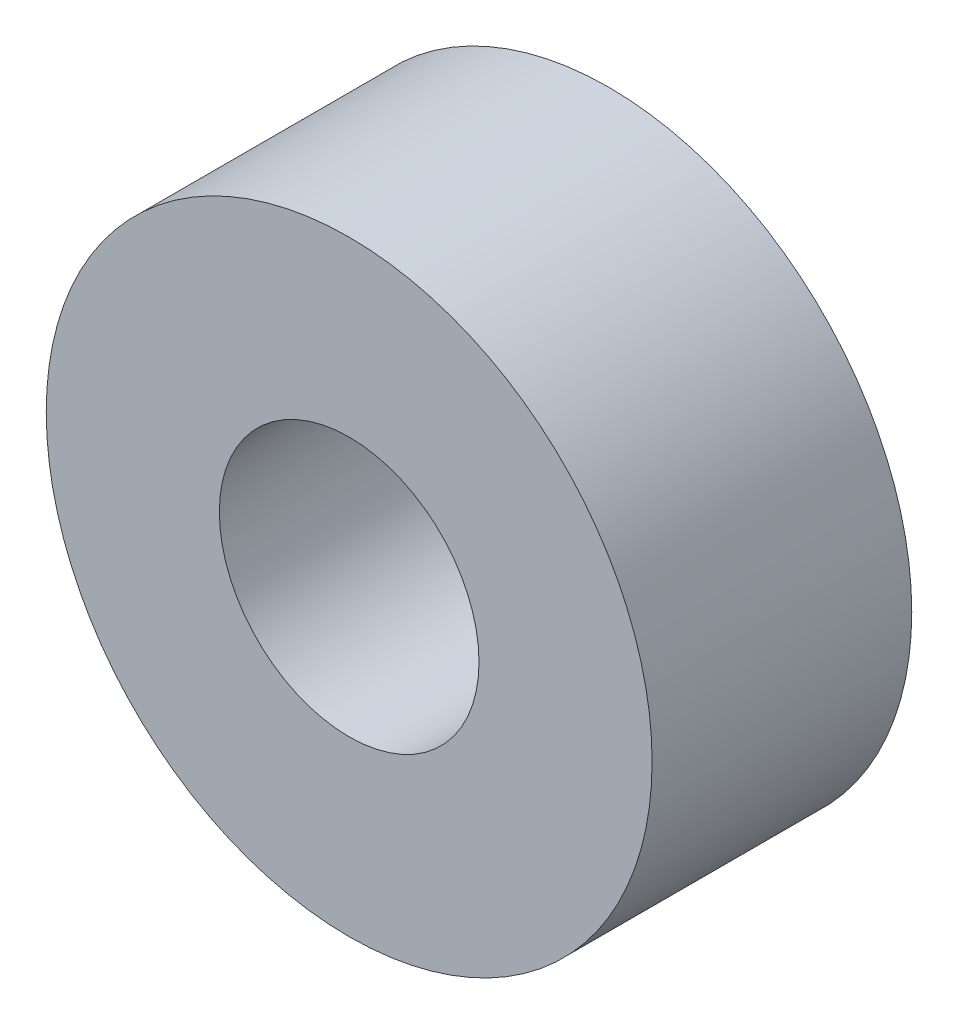
from build123d import *

# Parameters (mm, degrees)
ESQUISSE1_R        = 3.5
ESQUISSE1_R_2      = 1.5
BOSS_EXTRU_1_DEPTH = 3


with BuildPart() as part:
    # Esquisse1 → Boss.-Extru.1 (new body)
    with BuildSketch(Plane.XY):
        Circle(ESQUISSE1_R)
        Circle(ESQUISSE1_R_2, mode=Mode.SUBTRACT)
    extrude(amount=BOSS_EXTRU_1_DEPTH)


solid = part.part
